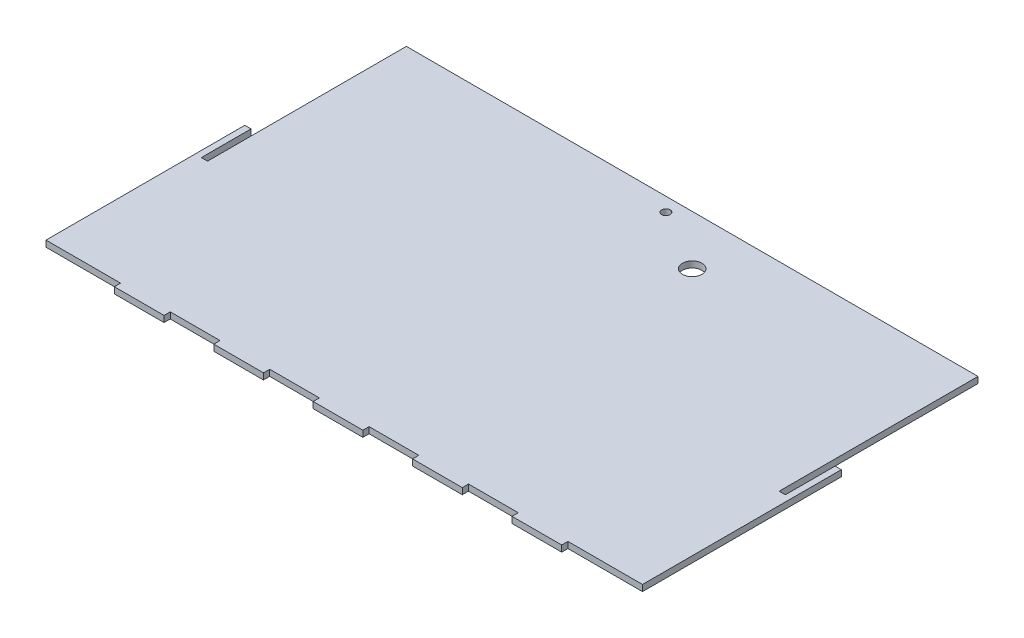
from build123d import *

# Parameters (mm, degrees)
SKETCH1_R           = 2.15
SKETCH1_R_2         = 4.953
SKETCH1_W           = 25.4
SKETCH1_H           = 3.175
BOSS_EXTRUDE1_DEPTH = 1.5875


with BuildPart() as part:
    # Sketch1 → Boss-Extrude1 (new body, symmetric)
    with BuildSketch(Plane(origin=(0, 0, 0), x_dir=(1, 0, 0), z_dir=(0, 1, 0))):
        Polygon((-152.4, 12.7), (-152.4, -88.9), (-114.3, -88.9), (-88.9, -88.9), (-63.5, -88.9), (-38.1, -88.9), (-12.7, -88.9), (12.7, -88.9), (38.1, -88.9), (63.5, -88.9), (88.9, -88.9), (114.3, -88.9), (152.4, -88.9), (152.4, 12.7), (149.225, 12.7), (149.225, -12.7), (146.05, -12.7), (146.05, 88.9), (-146.05, 88.9), (-146.05, -12.7), (-149.225, -12.7), (-149.225, 12.7), align=None)
        with Locations((-6.35, 81.8322)):
            Circle(SKETCH1_R, mode=Mode.SUBTRACT)
        with Locations((25.4, 63.5)):
            Circle(SKETCH1_R_2, mode=Mode.SUBTRACT)
        with Locations((-101.6, -90.4875)):
            Rectangle(SKETCH1_W, SKETCH1_H)
        with Locations((-50.8, -90.4875)):
            Rectangle(SKETCH1_W, SKETCH1_H)
        with Locations((0, -90.4875)):
            Rectangle(SKETCH1_W, SKETCH1_H)
        with Locations((50.8, -90.4875)):
            Rectangle(SKETCH1_W, SKETCH1_H)
        with Locations((101.6, -90.4875)):
            Rectangle(SKETCH1_W, SKETCH1_H)
    extrude(amount=BOSS_EXTRUDE1_DEPTH, both=True)


solid = part.part
